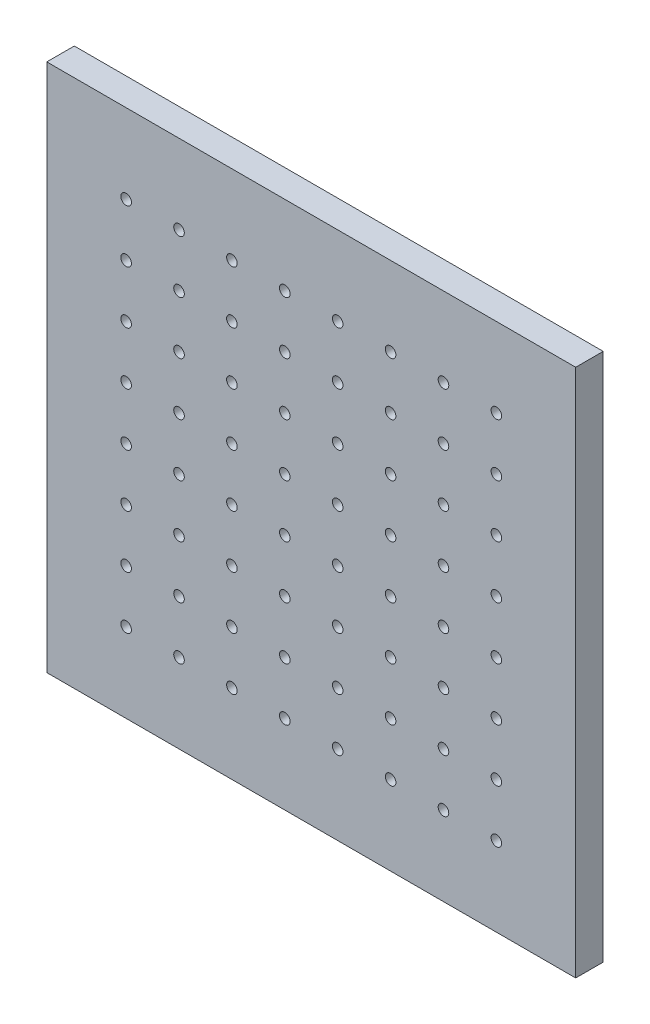
from build123d import *

# Parameters (mm, degrees)
SKETCH_1_W                  = 250
SKETCH_1_H                  = 250
EXTRUDE_1_DEPTH             = 13
HOLE_WIZARD_M6_1_D          = 5
PATTERN_LINEAR_1_COUNT      = 8
PATTERN_LINEAR_1_PITCH      = 25
PATTERN_LINEAR_1_COUNT_DIR2 = 8
PATTERN_LINEAR_1_PITCH_DIR2 = 25


with BuildPart() as part:
    # 草图1 → 凸台-拉伸1 (new body)
    with BuildSketch(Plane.XY):
        Rectangle(SKETCH_1_W, SKETCH_1_H)
    extrude(amount=EXTRUDE_1_DEPTH)

    # M6 螺纹孔的螺纹孔钻头1 (through all)
    with Locations(Plane.XY.offset(13)):
        with Locations((-87.5, -87.5)):
            hole_wizard_m6_1 = Hole(HOLE_WIZARD_M6_1_D / 2)

    # 阵列(线性)1: Hole Wizard M6 _1 8 × 8
    with Locations(*[(j * PATTERN_LINEAR_1_PITCH_DIR2, i * PATTERN_LINEAR_1_PITCH, 0) for i in range(PATTERN_LINEAR_1_COUNT) for j in range(PATTERN_LINEAR_1_COUNT_DIR2) if (i, j) != (0, 0)]):
        add(hole_wizard_m6_1, mode=Mode.SUBTRACT)


solid = part.part
